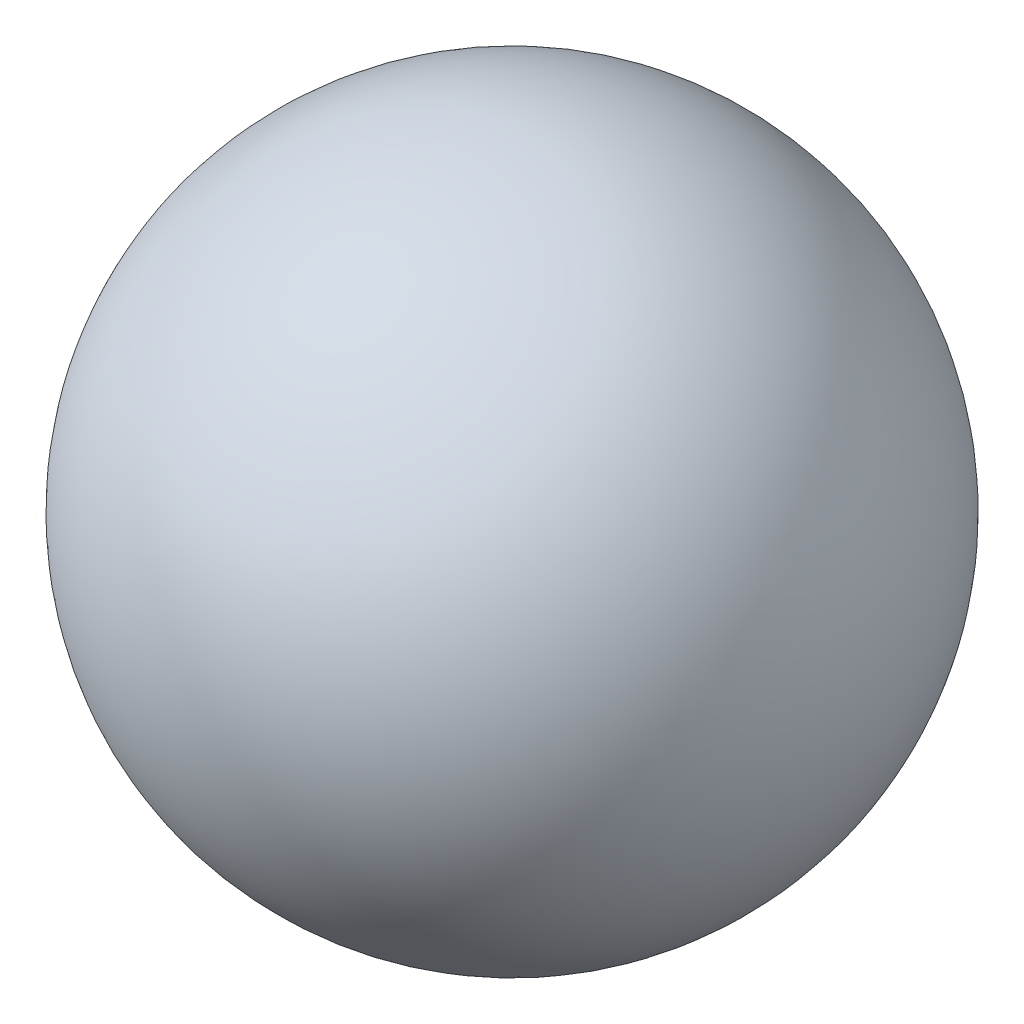
from build123d import *


with BuildPart() as part:
    # Croquis1 → Revolución1 (revolve)
    with BuildSketch(Plane.XY):
        with BuildLine():
            Line((10.572, 30), (3.428, 30))
            ThreePointArc((3.428, 30), (7, 33.572), (10.572, 30))
        make_face()
    revolve(axis=Axis((50, 30, 0), (-1, 0, 0)))


solid = part.part
